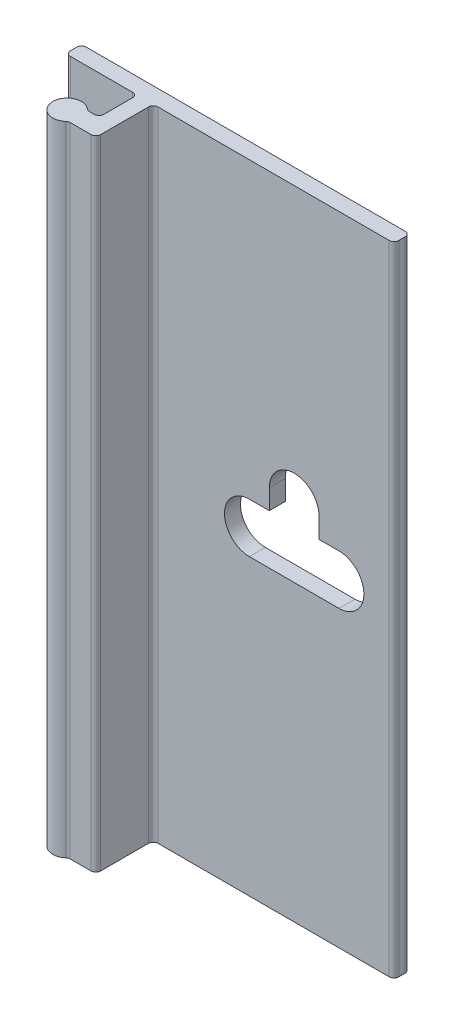
from build123d import *

# Parameters (mm, degrees)
BOSS_EXTRUDE1_DEPTH = 50.8
SKETCH4_W           = 2.921
SKETCH4_H           = 4.572
CUT_EXTRUDE2_DEPTH  = 51.8
FILLET1_R           = 0.381
CUT_EXTRUDE1_DEPTH  = 2.27


with BuildPart() as part:
    # Sketch2 → Boss-Extrude1 (new body)
    with BuildSketch(Plane(origin=(0, 0, 0), x_dir=(1, 0, 0), z_dir=(0, 1, 0))):
        with BuildLine():
            Line((-5.969, 0), (19.431, 0))
            ThreePointArc((19.431, 0), (19.700407684, -0.111592316), (19.812, -0.381))
            Line((19.812, -0.381), (19.812, -0.889))
            ThreePointArc((19.812, -0.889), (19.700407684, -1.158407684), (19.431, -1.27))
            Line((19.431, -1.27), (1.016, -1.27))
            ThreePointArc((1.016, -1.27), (0.746592316, -1.381592316), (0.635, -1.651))
            Line((0.635, -1.651), (0.635, -3.937))
            ThreePointArc((0.635, -3.937), (0.746592316, -4.206407684), (1.016, -4.318))
            Line((1.016, -4.318), (1.40496875, -4.318))
            ThreePointArc((1.40496875, -4.318), (1.539672592, -4.293392866), (1.656976563, -4.22275))
            ThreePointArc((1.656976563, -4.22275), (3.556, -5.08), (1.656976563, -5.93725))
            ThreePointArc((1.656976563, -5.93725), (1.539672592, -5.866607134), (1.40496875, -5.842))
            Line((1.40496875, -5.842), (-1.40496875, -5.842))
            ThreePointArc((-1.40496875, -5.842), (-1.539672592, -5.866607134), (-1.656976563, -5.93725))
            ThreePointArc((-1.656976563, -5.93725), (-3.556, -5.08), (-1.656976563, -4.22275))
            ThreePointArc((-1.656976563, -4.22275), (-1.539672592, -4.293392866), (-1.40496875, -4.318))
            Line((-1.40496875, -4.318), (-1.016, -4.318))
            ThreePointArc((-1.016, -4.318), (-0.746592316, -4.206407684), (-0.635, -3.937))
            Line((-0.635, -3.937), (-0.635, -1.651))
            ThreePointArc((-0.635, -1.651), (-0.746592316, -1.381592316), (-1.016, -1.27))
            Line((-1.016, -1.27), (-5.969, -1.27))
            ThreePointArc((-5.969, -1.27), (-6.238407684, -1.158407684), (-6.35, -0.889))
            Line((-6.35, -0.889), (-6.35, -0.381))
            ThreePointArc((-6.35, -0.381), (-6.238407684, -0.111592316), (-5.969, 0))
        make_face()
    extrude(amount=BOSS_EXTRUDE1_DEPTH)

    # Sketch4 → Cut-Extrude2 (cut, through all)
    with BuildSketch(Plane.XZ):
        with Locations((2.0955, 3.937)):
            Rectangle(SKETCH4_W, SKETCH4_H)
    extrude(amount=-CUT_EXTRUDE2_DEPTH, mode=Mode.SUBTRACT)

    # Fillet1
    fillet1_edges = [part.edges().sort_by_distance(p)[0] for p in [
        (0.635, 25.4, 5.842),
    ]]
    fillet(fillet1_edges, radius=FILLET1_R)

    # Sketch3 → Cut-Extrude1 (cut, through all)
    with BuildSketch(Plane.XY.offset(1.27)):
        with BuildLine():
            Line((8.2931, 27.3812), (9.8806, 27.3812))
            Line((9.8806, 27.3812), (9.8806, 28.9814))
            ThreePointArc((9.8806, 28.9814), (11.8618, 30.9626), (13.843, 28.9814))
            Line((13.843, 28.9814), (13.843, 27.3812))
            Line((13.843, 27.3812), (15.4305, 27.3812))
            ThreePointArc((15.4305, 27.3812), (17.4117, 25.4), (15.4305, 23.4188))
            Line((15.4305, 23.4188), (8.2931, 23.4188))
            ThreePointArc((8.2931, 23.4188), (6.3119, 25.4), (8.2931, 27.3812))
        make_face()
    extrude(amount=-CUT_EXTRUDE1_DEPTH, mode=Mode.SUBTRACT)


solid = part.part
